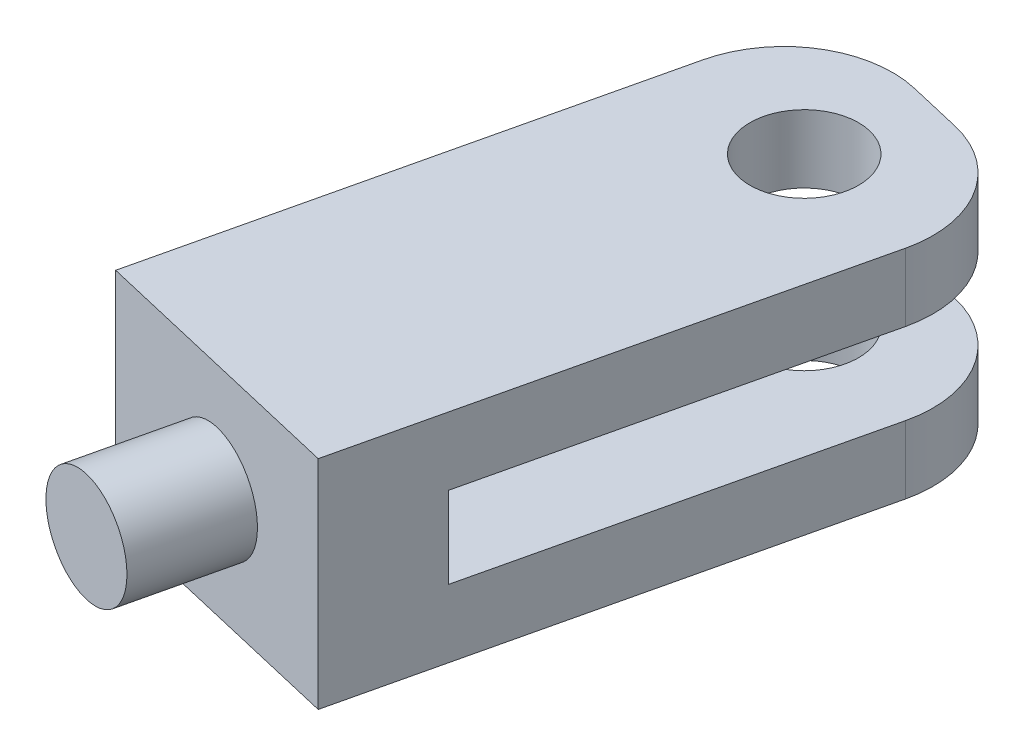
from build123d import *

# Parameters (mm, degrees)
SKETCH9_W           = 50
SKETCH9_H           = 110
BOSS_EXTRUDE3_DEPTH = 40
CUT_EXTRUDE4_DEPTH  = 90
FILLET2_R           = 20
SKETCH15_R          = 10
CUT_EXTRUDE5_DEPTH  = 41
SKETCH22_R          = 10
BOSS_EXTRUDE4_DEPTH = 20


with BuildPart() as part:
    # Sketch9 → Boss-Extrude3 (new body)
    with BuildSketch(Plane(origin=(-33.280188112, 0, 144.42881153), x_dir=(-0.973697035, 0, -0.227846622), z_dir=(0, 1, 0))):
        with Locations((25.502796398, -93.212684061)):
            Rectangle(SKETCH9_W, SKETCH9_H)
    extrude(amount=-BOSS_EXTRUDE3_DEPTH)

    # Sketch14 → Cut-Extrude4 (cut)
    with BuildSketch(Plane(origin=(1.578968454, -248.415731332, 0.369481077), x_dir=(0.949498442, -0.221555699, 0.222184114), z_dir=(-0.227846622, 0, 0.973697035))):
        Polygon((-102.607181661, 218.615622522), (-99.28384617, 203.988406751), (-50.526460266, 215.066191719), (-53.849795757, 229.69340749), align=None)
    extrude(amount=CUT_EXTRUDE4_DEPTH, mode=Mode.SUBTRACT)

    # Fillet2
    fillet2_edges = [part.edges().sort_by_distance(p)[0] for p in [
        (0, -6.25, 0),
        (-48.684851767, -6.25, -11.392331125),
        (-48.684851767, -33.75, -11.392331125),
        (0, -33.75, 0),
    ]]
    fillet(fillet2_edges, radius=FILLET2_R)

    # Sketch15 → Cut-Extrude5 (cut, through all)
    with BuildSketch(Plane(origin=(0, -40, 0), x_dir=(0.973697035, 0, 0.227846622), z_dir=(0, -1, 0))):
        with Locations((-25, 20)):
            Circle(SKETCH15_R)
    extrude(amount=-CUT_EXTRUDE5_DEPTH, mode=Mode.SUBTRACT)

    # Sketch22 → Boss-Extrude4 (add)
    with BuildSketch(Plane(origin=(-24.856078548, -32.574722266, 107.155123892), x_dir=(-0.94660116, -0.234267522, -0.221506145), z_dir=(-0.227846622, 0, 0.973697035))):
        with Locations((21.565180907, -18.131298438)):
            Circle(SKETCH22_R)
    extrude(amount=BOSS_EXTRUDE4_DEPTH)


solid = part.part
